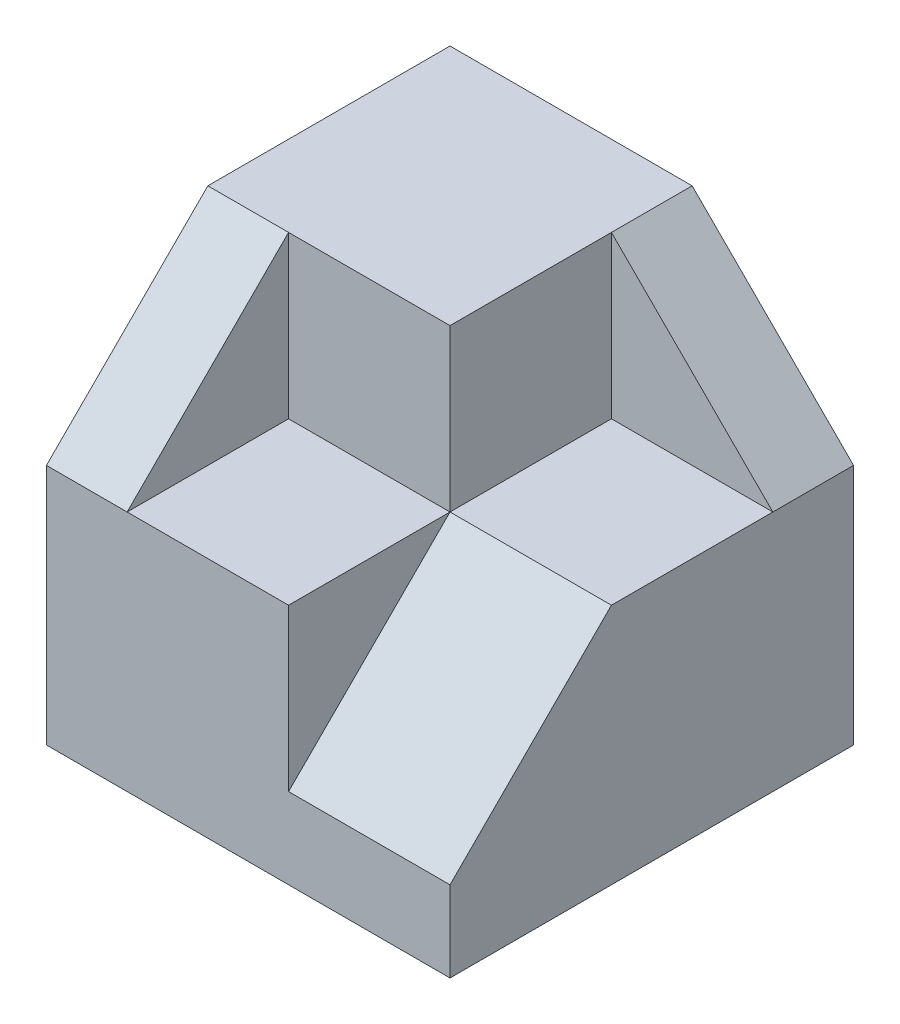
from build123d import *

# Parameters (mm, degrees)
SKETCH1_W           = 5
SKETCH1_H           = 5
BOSS_EXTRUDE1_DEPTH = 5
SKETCH2_W           = 4
SKETCH2_H           = 2
CUT_EXTRUDE1_DEPTH  = 2
SKETCH3_W           = 2
SKETCH3_H           = 2
CUT_EXTRUDE2_DEPTH  = 2
CUT_EXTRUDE3_DEPTH  = 2
CUT_EXTRUDE4_DEPTH  = 2
CUT_EXTRUDE5_DEPTH  = 2


with BuildPart() as part:
    # Sketch1 → Boss-Extrude1 (new body)
    with BuildSketch(Plane.XY):
        Rectangle(SKETCH1_W, SKETCH1_H)
    extrude(amount=BOSS_EXTRUDE1_DEPTH)

    # Sketch2 → Cut-Extrude1 (cut)
    with BuildSketch(Plane(origin=(0, 2.5, 0), x_dir=(1, 0, 0), z_dir=(0, 1, 0))):
        with Locations((0.5, -4)):
            Rectangle(SKETCH2_W, SKETCH2_H)
    extrude(amount=-CUT_EXTRUDE1_DEPTH, mode=Mode.SUBTRACT)

    # Sketch3 → Cut-Extrude2 (cut)
    with BuildSketch(Plane(origin=(0, 2.5, 0), x_dir=(1, 0, 0), z_dir=(0, 1, 0))):
        with Locations((1.5, -2)):
            Rectangle(SKETCH3_W, SKETCH3_H)
    extrude(amount=-CUT_EXTRUDE2_DEPTH, mode=Mode.SUBTRACT)

    # Sketch4 → Cut-Extrude3 (cut, through all)
    with BuildSketch(Plane.XY.offset(1)):
        Polygon((0.5, 2.5), (2.5, 0.5), (2.5, 2.5), align=None)
    extrude(amount=-CUT_EXTRUDE3_DEPTH, mode=Mode.SUBTRACT)

    # Sketch5 → Cut-Extrude4 (cut)
    with BuildSketch(Plane(origin=(2.5, 0, 0), x_dir=(0, 0, -1), z_dir=(1, 0, 0))):
        Polygon((-5, 0.5), (-3, 0.5), (-5, -1.5), align=None)
    extrude(amount=-CUT_EXTRUDE4_DEPTH, mode=Mode.SUBTRACT)

    # Sketch6 → Cut-Extrude5 (cut, through all)
    with BuildSketch(Plane(origin=(-1.5, 0, 0), x_dir=(0, 0, -1), z_dir=(1, 0, 0))):
        Polygon((-3, 2.5), (-5, 0.5), (-5, 2.5), align=None)
    extrude(amount=-CUT_EXTRUDE5_DEPTH, mode=Mode.SUBTRACT)


solid = part.part
